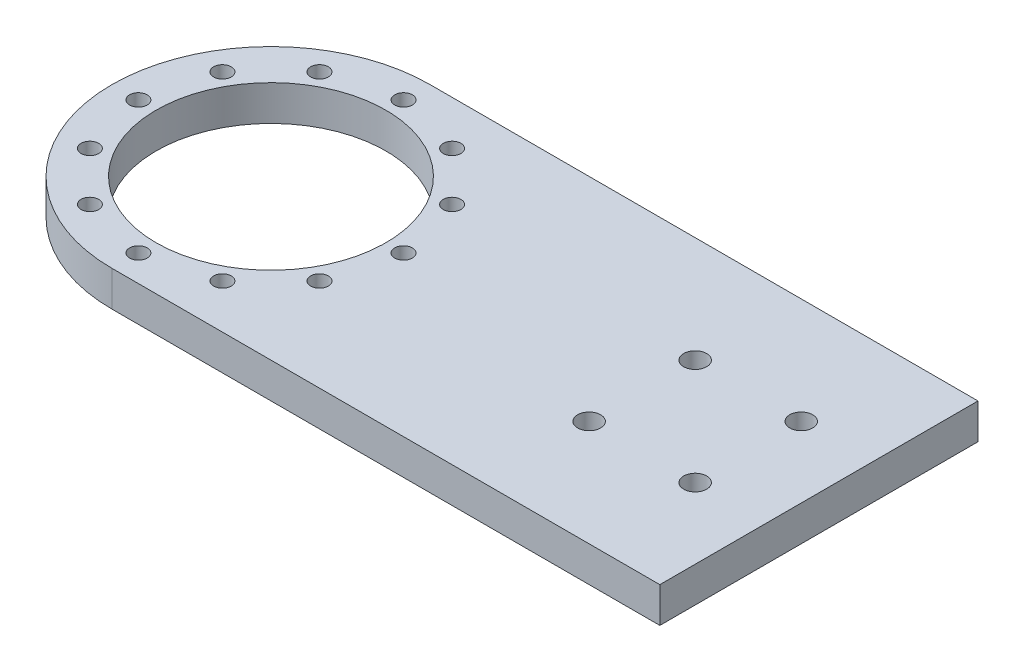
from build123d import *

# Parameters (mm, degrees)
BOSS_EXTRUDE1_DEPTH = 10
SKETCH2_R           = 2.5
SKETCH2_R_2         = 32.5
CUT_EXTRUDE1_DEPTH  = 11
SKETCH3_R           = 3.25
CUT_EXTRUDE2_DEPTH  = 11


with BuildPart() as part:
    # Sketch1 → Boss-Extrude1 (new body)
    with BuildSketch(Plane(origin=(0, 0, 0), x_dir=(1, 0, 0), z_dir=(0, 1, 0))):
        with BuildLine():
            Line((100, 45), (-55, 45))
            ThreePointArc((-55, 45), (-100, 0), (-55, -45))
            Line((-55, -45), (100, -45))
            Line((100, -45), (100, 45))
        make_face()
    extrude(amount=BOSS_EXTRUDE1_DEPTH)

    # Sketch2 → Cut-Extrude1 (cut, through all)
    with BuildSketch(Plane(origin=(0, 10, 0), x_dir=(1, 0, 0), z_dir=(0, 1, 0))):
        with Locations((-92.5, 0)):
            Circle(SKETCH2_R)
        with Locations((-87.475952642, 18.75)):
            Circle(SKETCH2_R)
        with Locations((-73.75, 32.475952642)):
            Circle(SKETCH2_R)
        with Locations((-55, 0)):
            Circle(SKETCH2_R_2)
        with Locations((-55, 37.5)):
            Circle(SKETCH2_R)
        with Locations((-36.25, 32.475952642)):
            Circle(SKETCH2_R)
        with Locations((-22.524047358, 18.75)):
            Circle(SKETCH2_R)
        with Locations((-17.5, 0)):
            Circle(SKETCH2_R)
        with Locations((-22.524047358, -18.75)):
            Circle(SKETCH2_R)
        with Locations((-36.25, -32.475952642)):
            Circle(SKETCH2_R)
        with Locations((-55, -37.5)):
            Circle(SKETCH2_R)
        with Locations((-73.75, -32.475952642)):
            Circle(SKETCH2_R)
        with Locations((-87.475952642, -18.75)):
            Circle(SKETCH2_R)
    extrude(amount=-CUT_EXTRUDE1_DEPTH, mode=Mode.SUBTRACT)

    # Sketch3 → Cut-Extrude2 (cut, through all)
    with BuildSketch(Plane(origin=(0, 10, 0), x_dir=(1, 0, 0), z_dir=(0, 1, 0))):
        with Locations((80, 15)):
            Circle(SKETCH3_R)
        with Locations((50, 15)):
            Circle(SKETCH3_R)
        with Locations((50, -15)):
            Circle(SKETCH3_R)
        with Locations((80, -15)):
            Circle(SKETCH3_R)
    extrude(amount=-CUT_EXTRUDE2_DEPTH, mode=Mode.SUBTRACT)


solid = part.part
